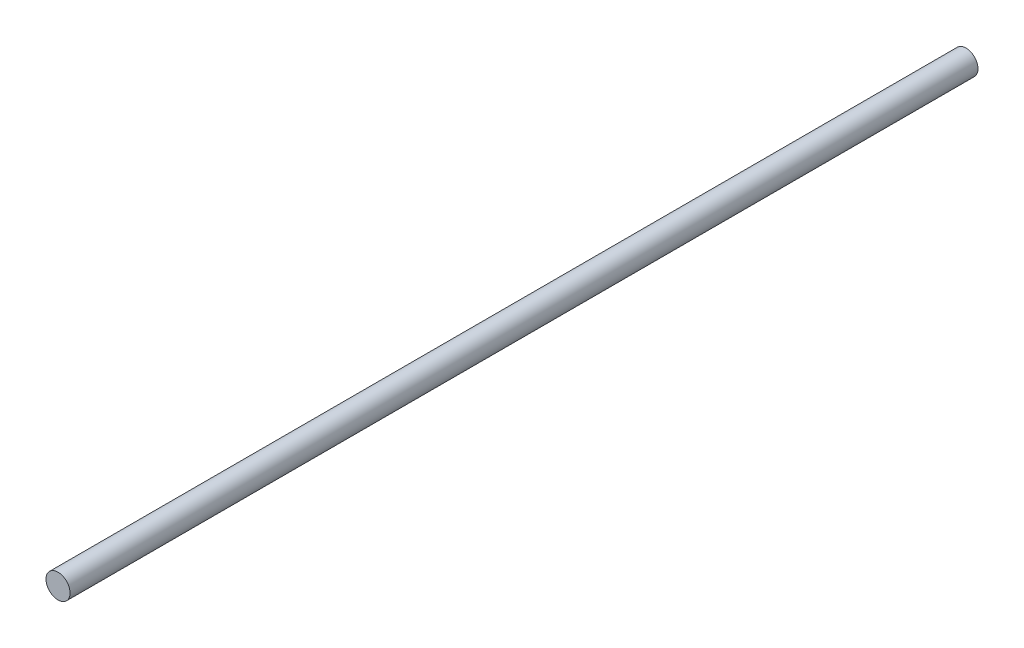
from build123d import *

# Parameters (mm, degrees)
SKETCH_1_R      = 0.325
EXTRUDE_1_DEPTH = 24.5


with BuildPart() as part:
    # 草图1 → 凸台-拉伸1 (new body)
    with BuildSketch(Plane.XY):
        Circle(SKETCH_1_R)
    extrude(amount=EXTRUDE_1_DEPTH)


solid = part.part
